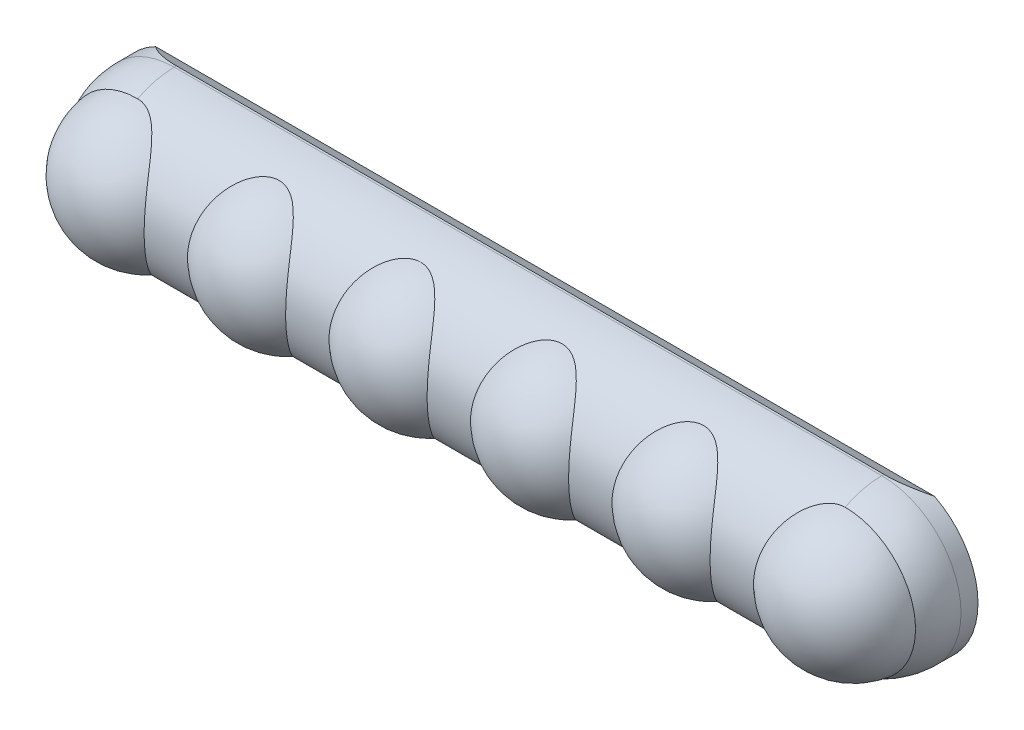
from build123d import *

# Parameters (mm, degrees)
REVOLVE1_ANGLE          = 180
REVOLVE2_ANGLE          = 180
LPATTERN1_COUNT         = 6
LPATTERN1_PITCH         = 25
BOSS_EXTRUDE1_DEPTH     = 3
CUT_EXTRUDE4_DEPTH      = 77.5
CUT_EXTRUDE4_DEPTH_BACK = 77.5
SKETCH6_R               = 2.6
CUT_EXTRUDE5_DEPTH      = 8
SKETCH7_W               = 46.5
SKETCH7_H               = 12
CUT_EXTRUDE6_DEPTH      = 8


with BuildPart() as part:
    # Sketch1 → Revolve1 (revolve)
    with BuildSketch(Plane.XY):
        with BuildLine():
            Line((62.5, 14), (-62.5, 14))
            ThreePointArc((-62.5, 14), (-72.399494937, 9.899494937), (-76.5, 0))
            Line((-76.5, 0), (76.5, 0))
            ThreePointArc((76.5, 0), (72.399494937, 9.899494937), (62.5, 14))
        make_face()
    revolve(axis=Axis((-76.5, 0, 0), (1, 0, 0)), revolution_arc=REVOLVE1_ANGLE)

    # Sketch3 → Revolve2 (revolve)
    with BuildSketch(Plane.XY.offset(5)):
        with BuildLine():
            Line((-75, 0), (-50, 0))
            ThreePointArc((-50, 0), (-62.5, 12.5), (-75, 0))
        make_face()
    revolve2 = revolve(axis=Axis((-75, 0, 5), (1, 0, 0)), revolution_arc=REVOLVE2_ANGLE)

    # LPattern1: Revolve2 ×6
    with Locations(*[(i * LPATTERN1_PITCH, 0, 0) for i in range(1, LPATTERN1_COUNT)]):
        add(revolve2)

    # Sketch4 → Boss-Extrude1 (add)
    with BuildSketch(Plane(origin=(0, 0, 0), x_dir=(-1, 0, 0), z_dir=(0, 0, -1))):
        with BuildLine():
            Line((-62.5, -14), (62.5, -14))
            ThreePointArc((62.5, -14), (76.5, 0), (62.5, 14))
            Line((62.5, 14), (-62.5, 14))
            ThreePointArc((-62.5, 14), (-76.5, 0), (-62.5, -14))
        make_face()
    extrude(amount=BOSS_EXTRUDE1_DEPTH)

    # Sketch5 → Cut-Extrude4 (cut, two sides)
    with BuildSketch(Plane(origin=(0, 0, 0), x_dir=(0, 0, -1), z_dir=(1, 0, 0))) as cut_extrude4_sk:
        Polygon((0.398662505, 13.994322713), (0.398662505, 14.646589276), (3, 14.646589276), (3, 12.5), align=None)
        Polygon((3, -14), (0.398662505, -14), (3, -12.5), align=None)
    extrude(amount=CUT_EXTRUDE4_DEPTH, mode=Mode.SUBTRACT)
    extrude(cut_extrude4_sk.sketch, amount=-CUT_EXTRUDE4_DEPTH_BACK, mode=Mode.SUBTRACT)

    # Sketch6 → Cut-Extrude5 (cut)
    with BuildSketch(Plane(origin=(0, 0, -3), x_dir=(-1, 0, 0), z_dir=(0, 0, -1))):
        with Locations(Location((0, 0, 0), (0, 0, 90))):  # turned: the seam where the file's is
            Circle(SKETCH6_R)
        with Locations(Location((62.5, 0, 0), (0, 0, 90))):  # turned: the seam where the file's is
            Circle(SKETCH6_R)
        with Locations(Location((-62.5, 0, 0), (0, 0, 90))):  # turned: the seam where the file's is
            Circle(SKETCH6_R)
    extrude(amount=-CUT_EXTRUDE5_DEPTH, mode=Mode.SUBTRACT)

    # Sketch7 → Cut-Extrude6 (cut)
    with BuildSketch(Plane(origin=(0, 0, -3), x_dir=(-1, 0, 0), z_dir=(0, 0, -1))):
        with Locations((-31.25, 0)):
            Rectangle(SKETCH7_W, SKETCH7_H)
        with Locations((31.25, 0)):
            Rectangle(SKETCH7_W, SKETCH7_H)
    extrude(amount=-CUT_EXTRUDE6_DEPTH, mode=Mode.SUBTRACT)


solid = part.part
